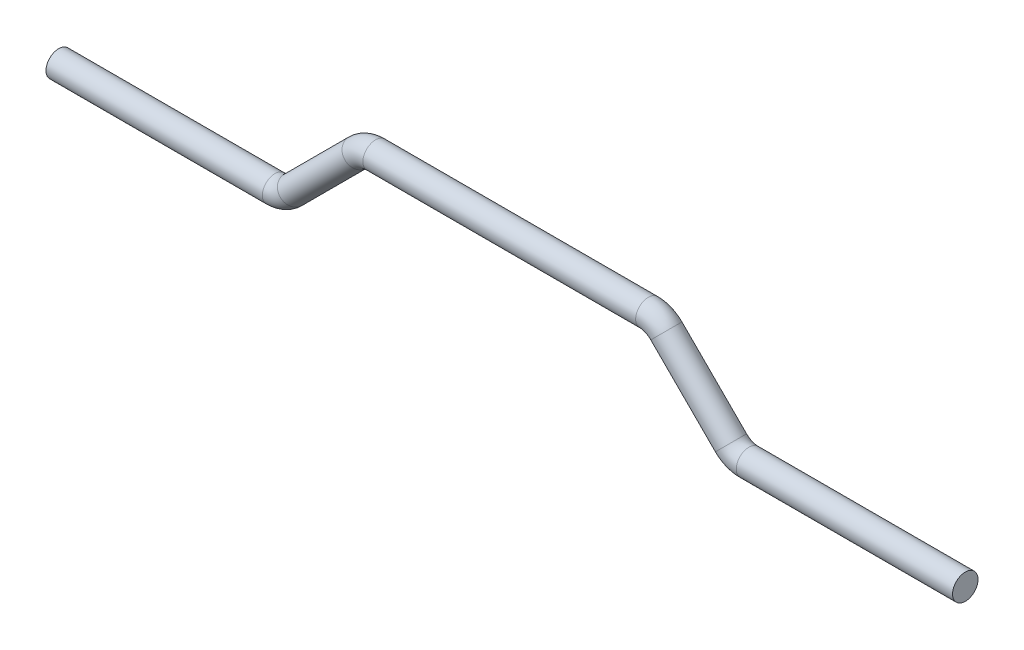
from build123d import *

# Parameters (mm, degrees)
SKETCH2_R = 4


with BuildPart() as part:
    # Base-Sweep: sweep along a path in Sketch1
    with BuildLine(Plane.XY) as base_sweep_path:
        Line((-142.5, -25), (-74.5, -25))
        ThreePointArc((-74.5, -25), (-71.438532541, -24.39103626), (-68.843145751, -22.656854249))
        Line((-68.843145751, -22.656854249), (-48.529437252, -2.343145751))
        ThreePointArc((-48.529437252, -2.343145751), (-45.934050461, -0.60896374), (-42.872583002, 0))
        Line((-42.872583002, 0), (42.872583002, 0))
        ThreePointArc((42.872583002, 0), (45.934050461, -0.60896374), (48.529437252, -2.343145751))
        Line((48.529437252, -2.343145751), (68.843145751, -22.656854249))
        ThreePointArc((68.843145751, -22.656854249), (71.438532541, -24.39103626), (74.5, -25))
        Line((74.5, -25), (142.5, -25))
    # Sketch2 → Base-Sweep (sweep)
    with BuildSketch(Plane(origin=(-142.5, -25, 0), x_dir=(0, 0, 1), z_dir=(-1, 0, 0))):
        Circle(SKETCH2_R)
    sweep(path=base_sweep_path.line)


solid = part.part
